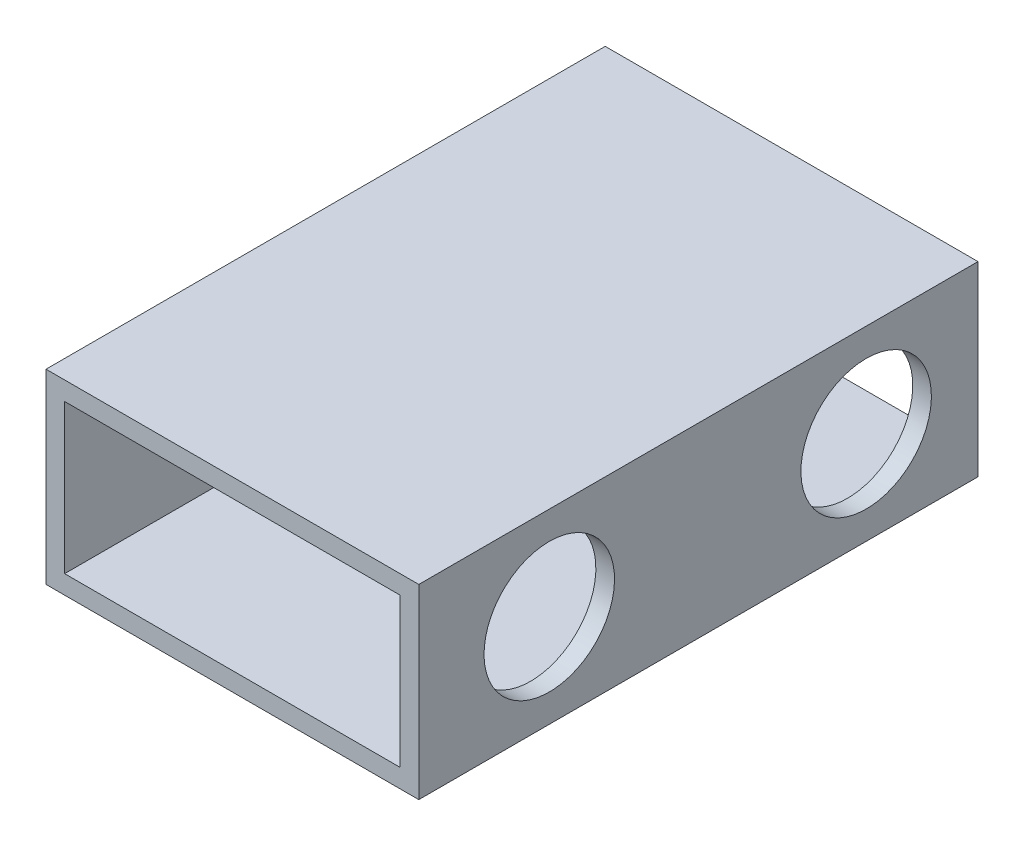
from build123d import *

# Parameters (mm, degrees)
SKETCH_1_W          = 20
SKETCH_1_H          = 10
SKETCH_1_W_2        = 18
SKETCH_1_H_2        = 8
EXTRUDE_1_DEPTH     = 30
SKETCH_2_R          = 1.5
CUT_EXTRUDE_1_DEPTH = 20
SKETCH_3_R          = 3.5
CUT_EXTRUDE_2_DEPTH = 5


with BuildPart() as part:
    # 草图1 → 拉伸-薄壁1 (new body)
    with BuildSketch(Plane.XY):
        with Locations((19.212936099, 31.397704236)):
            Rectangle(SKETCH_1_W, SKETCH_1_H)
        with Locations((19.212936099, 31.397704236)):
            Rectangle(SKETCH_1_W_2, SKETCH_1_H_2, mode=Mode.SUBTRACT)
    extrude(amount=EXTRUDE_1_DEPTH)

    # 草图2 → 切除-拉伸1 (cut)
    with BuildSketch(Plane(origin=(29.212936099, 0, 0), x_dir=(0, 0, -1), z_dir=(1, 0, 0))):
        with Locations((-23, 31.397704236)):
            Circle(SKETCH_2_R)
        with Locations((-6, 31.397704236)):
            Circle(SKETCH_2_R)
    extrude(amount=-CUT_EXTRUDE_1_DEPTH, mode=Mode.SUBTRACT)

    # 草图3 → 切除-拉伸2 (cut)
    with BuildSketch(Plane(origin=(29.212936099, 0, 0), x_dir=(0, 0, -1), z_dir=(1, 0, 0))):
        with Locations((-23, 31.397704236)):
            Circle(SKETCH_3_R)
        with Locations((-6, 31.397704236)):
            Circle(SKETCH_3_R)
    extrude(amount=-CUT_EXTRUDE_2_DEPTH, mode=Mode.SUBTRACT)


solid = part.part
